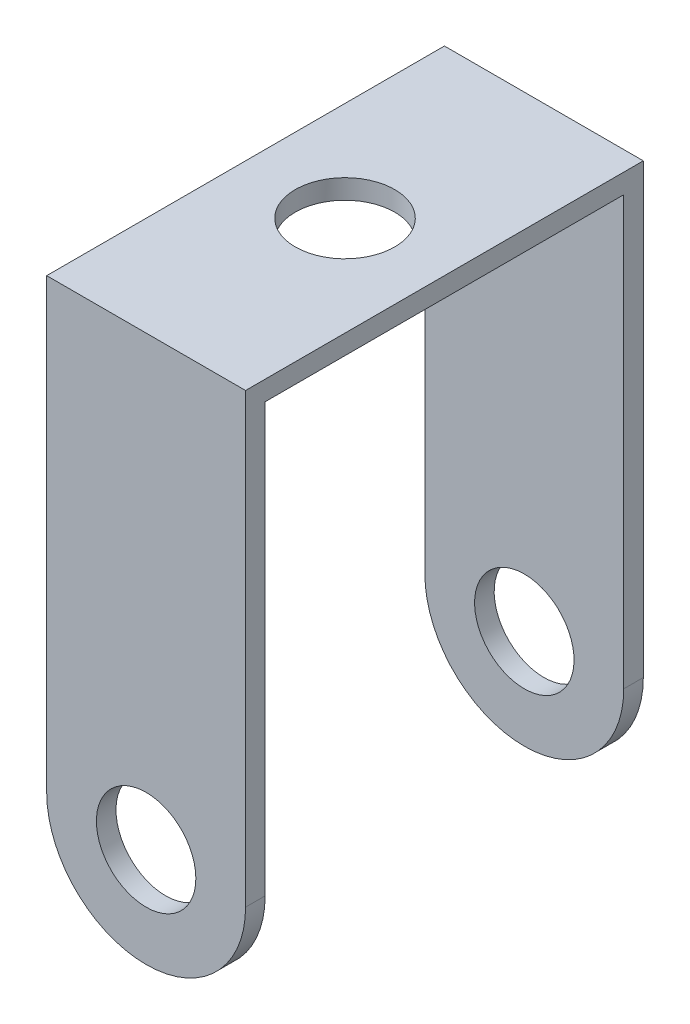
from build123d import *

# Parameters (mm, degrees)
SKETCH1_R           = 12.7
BOSS_EXTRUDE1_DEPTH = 50.8
SKETCH2_W           = 91.6
SKETCH2_H           = 134.7
CUT_EXTRUDE1_DEPTH  = 101.6
SKETCH3_R           = 12.7
CUT_EXTRUDE2_DEPTH  = 101.6


with BuildPart() as part:
    # Sketch1 → Boss-Extrude1 (new, symmetric)
    with BuildSketch(Plane.XY):
        with BuildLine():
            Line((-25.4, 0), (-25.4, 114.3))
            Line((-25.4, 114.3), (25.4, 114.3))
            Line((25.4, 114.3), (25.4, 0))
            ThreePointArc((25.4, 0), (0, -25.4), (-25.4, 0))
        make_face()
        Circle(SKETCH1_R, mode=Mode.SUBTRACT)
    extrude(amount=BOSS_EXTRUDE1_DEPTH, both=True)

    # Sketch2 → Cut-Extrude1 (cut)
    with BuildSketch(Plane(origin=(25.4, 0, 0), x_dir=(0, 0, -1), z_dir=(1, 0, 0))):
        with Locations((0, 41.95)):
            Rectangle(SKETCH2_W, SKETCH2_H)
    extrude(amount=-CUT_EXTRUDE1_DEPTH, mode=Mode.SUBTRACT)

    # Sketch3 → Cut-Extrude2 (cut)
    with BuildSketch(Plane(origin=(0, 114.3, 0), x_dir=(1, 0, 0), z_dir=(0, 1, 0))):
        Circle(SKETCH3_R)
    extrude(amount=-CUT_EXTRUDE2_DEPTH, mode=Mode.SUBTRACT)


solid = part.part
